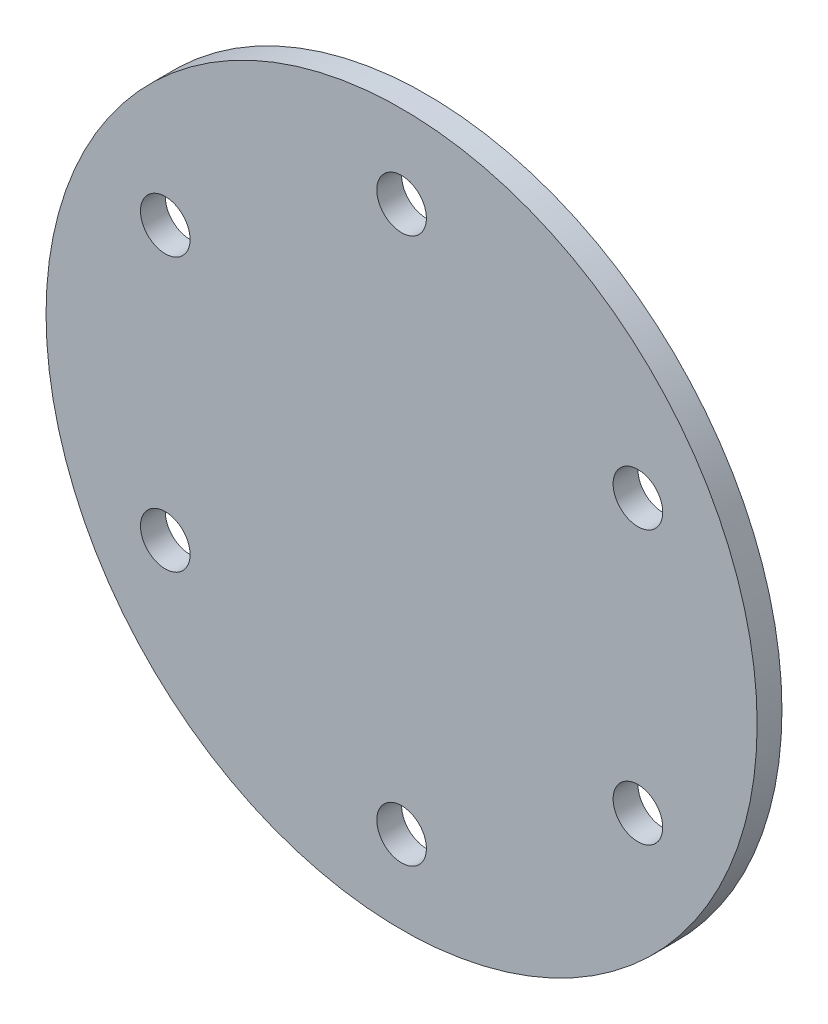
from build123d import *

# Parameters (mm, degrees)
SKETCH1_R           = 43
BOSS_EXTRUDE2_DEPTH = 3
SKETCH1_3_R         = 3
CUT_EXTRUDE1_DEPTH  = 61.88513776
CIRPATTERN2_COUNT   = 6


with BuildPart() as part:
    # Sketch1 → Boss-Extrude2 (new body)
    with BuildSketch(Plane.XY):
        Circle(SKETCH1_R)
    extrude(amount=BOSS_EXTRUDE2_DEPTH)

    # Sketch1_3 → Cut-Extrude1 (cut, through all)
    with BuildSketch(Plane.XY):
        with Locations((0, 33)):
            Circle(SKETCH1_3_R)
    cut_extrude1 = extrude(amount=CUT_EXTRUDE1_DEPTH, mode=Mode.SUBTRACT)

    # CirPattern2: Cut-Extrude1 ×6 about axis
    cirpattern2_axis = Axis((0, 0, 3), (0, 0, -1))
    for i in range(1, CIRPATTERN2_COUNT):
        add(cut_extrude1.rotate(cirpattern2_axis, i * 360 / CIRPATTERN2_COUNT), mode=Mode.SUBTRACT)


solid = part.part
